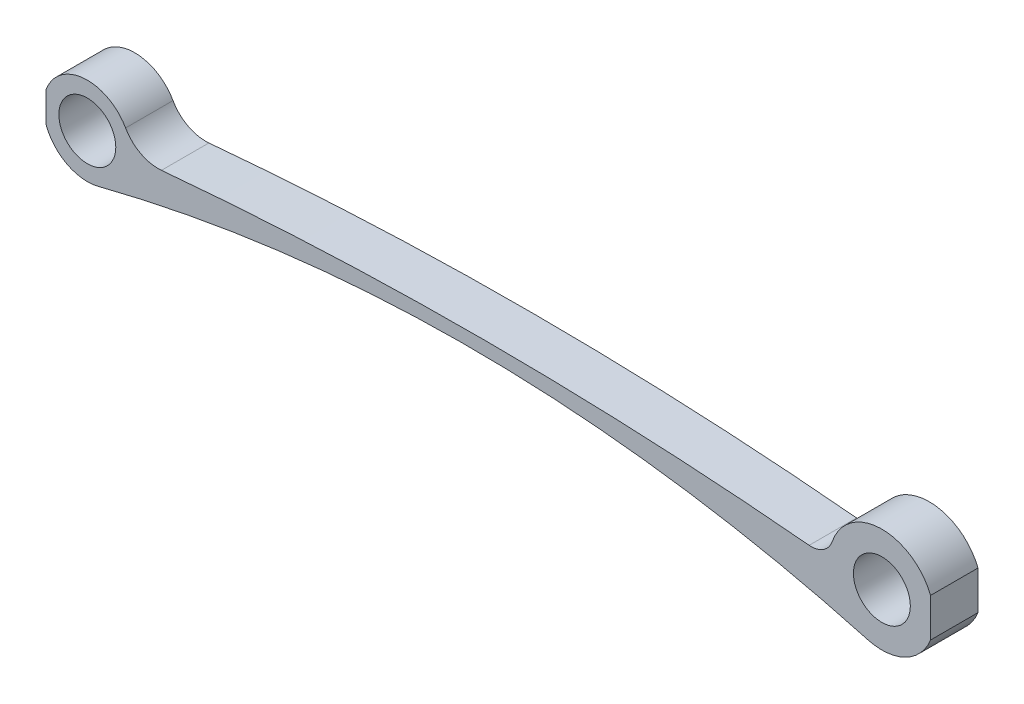
from build123d import *

# Parameters (mm, degrees)
SZKIC1_R                    = 3.000000079
DODANIE_WYCI_GNI_CIE1_DEPTH = 5
SZKIC2_W                    = 105.552332286
SZKIC2_H                    = 7.505645785
SZKIC2_W_2                  = 0.651830256
SZKIC2_H_2                  = 5.051684483
WYTNIJ_WYCI_GNI_CIE3_DEPTH  = 6


with BuildPart() as part:
    # Szkic1 → Dodanie-wyciągnięcie1 (new body)
    with BuildSketch(Plane.XY):
        with BuildLine():
            ThreePointArc((82.288446866, -5.322288535), (88.646994763, 2.576863373), (78.537310202, 1.78818708))
            ThreePointArc((78.537310202, 1.78818708), (77.588574134, 0.574418105), (76.092138721, 0.208335732))
            ThreePointArc((76.092138721, 0.208335732), (41.955082096, 1.834260744), (7.813610577, 0.303839332))
            ThreePointArc((7.813610577, 0.303839332), (5.63200922, 0.736314196), (4.033915145, 2.283089654))
            ThreePointArc((4.033915145, 2.283089654), (-4.263785422, 1.817994402), (1.14538756, -4.491442653))
            ThreePointArc((1.14538756, -4.491442653), (41.771214226, 0.395953927), (82.288446866, -5.322288535))
        make_face()
        Circle(SZKIC1_R, mode=Mode.SUBTRACT)
        with Locations((83.76241555, 0)):
            Circle(SZKIC1_R, mode=Mode.SUBTRACT)
    extrude(amount=DODANIE_WYCI_GNI_CIE1_DEPTH)

    # Szkic2 → Wytnij-wyciągnięcie3 (cut, through all)
    with BuildSketch(Plane.XY):
        with Locations((141.671704443, 0.381285041)):
            Rectangle(SZKIC2_W, SZKIC2_H)
        with Locations((-4.682734605, -0.038745932)):
            Rectangle(SZKIC2_W_2, SZKIC2_H_2)
    extrude(amount=WYTNIJ_WYCI_GNI_CIE3_DEPTH, mode=Mode.SUBTRACT)


solid = part.part
